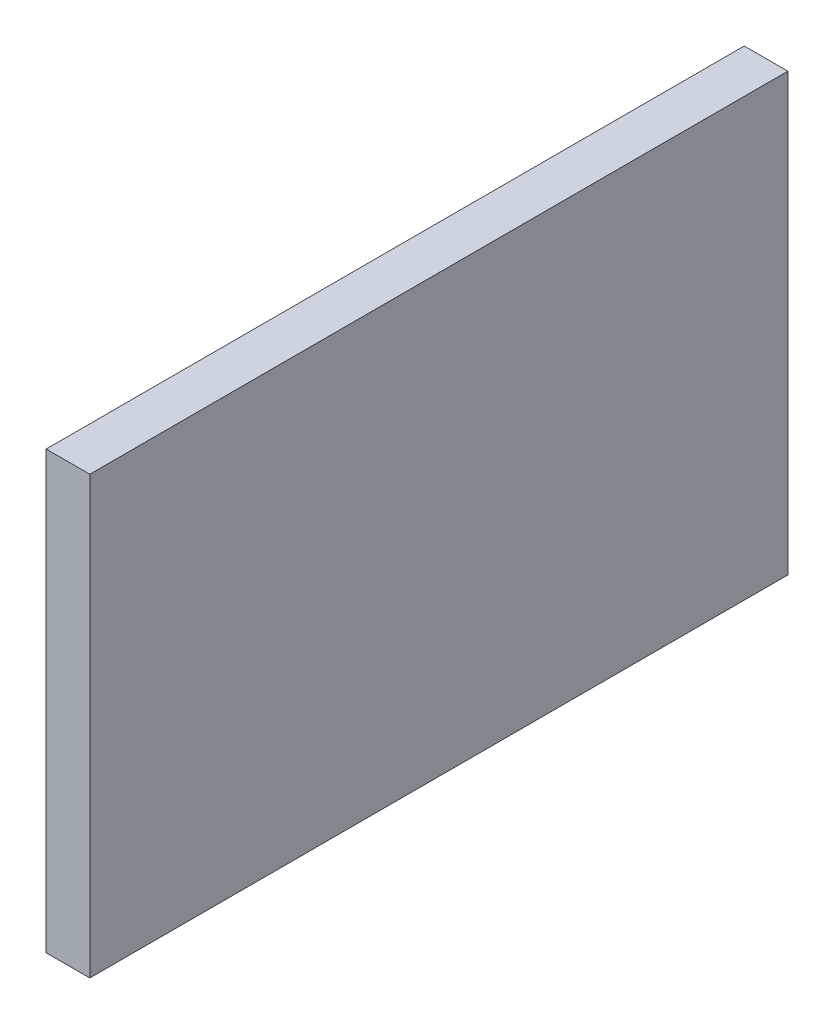
from build123d import *

# Parameters (mm, degrees)
SKETCH1_W           = 50.8
SKETCH1_H           = 31.75
BOSS_EXTRUDE1_DEPTH = 3.175


with BuildPart() as part:
    # Sketch1 → Boss-Extrude1 (new body)
    with BuildSketch(Plane(origin=(0, 0, 0), x_dir=(0, 0, -1), z_dir=(1, 0, 0))):
        Rectangle(SKETCH1_W, SKETCH1_H)
    extrude(amount=BOSS_EXTRUDE1_DEPTH)


solid = part.part
